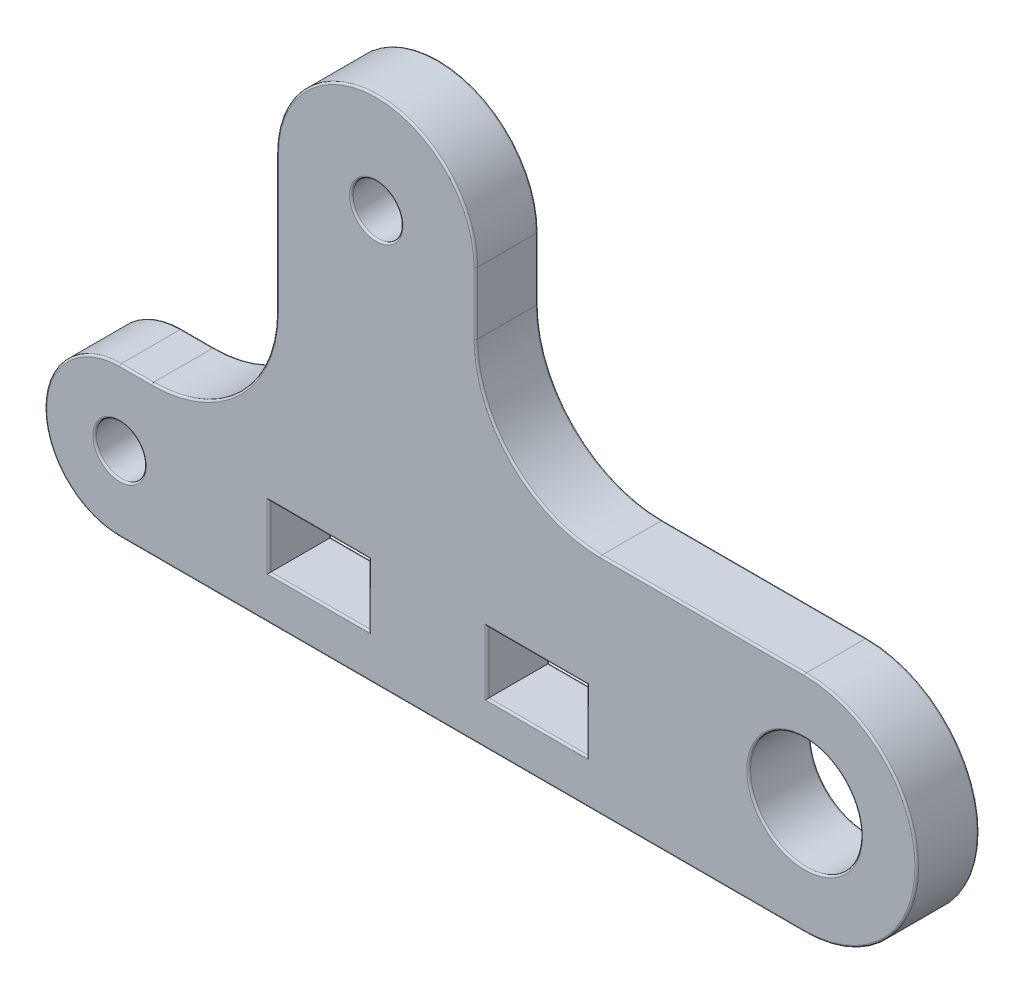
from build123d import *

# Parameters (mm, degrees)
SZKIC1_R                    = 2
SZKIC1_R_2                  = 4.5
SZKIC1_W                    = 8
SZKIC1_H                    = 5
DODANIE_WYCI_GNI_CIE1_DEPTH = 2.5
ZAOKR_GLENIE1_R             = 0.15


with BuildPart() as part:
    # Szkic1 → Dodanie-wyciągnięcie1 (new body, symmetric)
    with BuildSketch(Plane.XY):
        with BuildLine():
            Line((-27.5, 0), (27.5, 0))
            ThreePointArc((27.5, 0), (36.5, 9), (27.5, 18))
            Line((27.5, 18), (11.1, 18))
            ThreePointArc((11.1, 18), (4.028932188, 20.928932188), (1.1, 28))
            Line((1.1, 28), (1.1, 33))
            ThreePointArc((1.1, 33), (-6.9, 41), (-14.9, 33))
            Line((-14.9, 33), (-14.9, 22))
            ThreePointArc((-14.9, 22), (-17.828932188, 14.928932188), (-24.9, 12))
            Line((-24.9, 12), (-27.5, 12))
            ThreePointArc((-27.5, 12), (-33.5, 6), (-27.5, 0))
        make_face()
        with Locations((-27.5, 6)):
            Circle(SZKIC1_R, mode=Mode.SUBTRACT)
        with Locations((27.5, 9)):
            Circle(SZKIC1_R_2, mode=Mode.SUBTRACT)
        with Locations((-6.9, 33)):
            Circle(SZKIC1_R, mode=Mode.SUBTRACT)
        with Locations((-11.5, 6)):
            Rectangle(SZKIC1_W, SZKIC1_H, mode=Mode.SUBTRACT)
        with Locations((6, 6)):
            Rectangle(SZKIC1_W, SZKIC1_H, mode=Mode.SUBTRACT)
    extrude(amount=DODANIE_WYCI_GNI_CIE1_DEPTH, both=True)

    # Zaokrąglenie1
    zaokr_glenie1_edges = [part.edges().sort_by_distance(p)[0] for p in [
        (36.5, 9, 2.5),
        (-14.9, 27.5, -2.5),
        (-6.9, 41, -2.5),
        (1.1, 30.5, -2.5),
        (4.028932188, 20.928932188, -2.5),
        (19.3, 18, -2.5),
        (36.5, 9, -2.5),
        (0, 0, -2.5),
        (-33.5, 6, -2.5),
        (19.3, 18, 2.5),
        (4.028932188, 20.928932188, 2.5),
        (1.1, 30.5, 2.5),
        (-6.9, 41, 2.5),
        (-14.9, 27.5, 2.5),
        (23, 9, -2.5),
        (23, 9, 2.5),
        (-17.828932188, 14.928932188, 2.5),
        (-29.5, 6, -2.5),
        (-29.5, 6, 2.5),
        (-26.2, 12, 2.5),
        (-8.9, 33, -2.5),
        (-8.9, 33, 2.5),
        (-15.5, 6, -2.5),
        (-11.5, 3.5, -2.5),
        (-33.5, 6, 2.5),
        (-7.5, 6, -2.5),
        (-11.5, 8.5, -2.5),
        (-15.5, 6, 2.5),
        (-11.5, 3.5, 2.5),
        (-7.5, 6, 2.5),
        (-11.5, 8.5, 2.5),
        (2, 6, -2.5),
        (6, 3.5, -2.5),
        (10, 6, -2.5),
        (6, 8.5, -2.5),
        (2, 6, 2.5),
        (6, 3.5, 2.5),
        (10, 6, 2.5),
        (6, 8.5, 2.5),
        (0, 0, 2.5),
        (-26.2, 12, -2.5),
        (-17.828932188, 14.928932188, -2.5),
    ]]
    fillet(zaokr_glenie1_edges, radius=ZAOKR_GLENIE1_R)


solid = part.part
